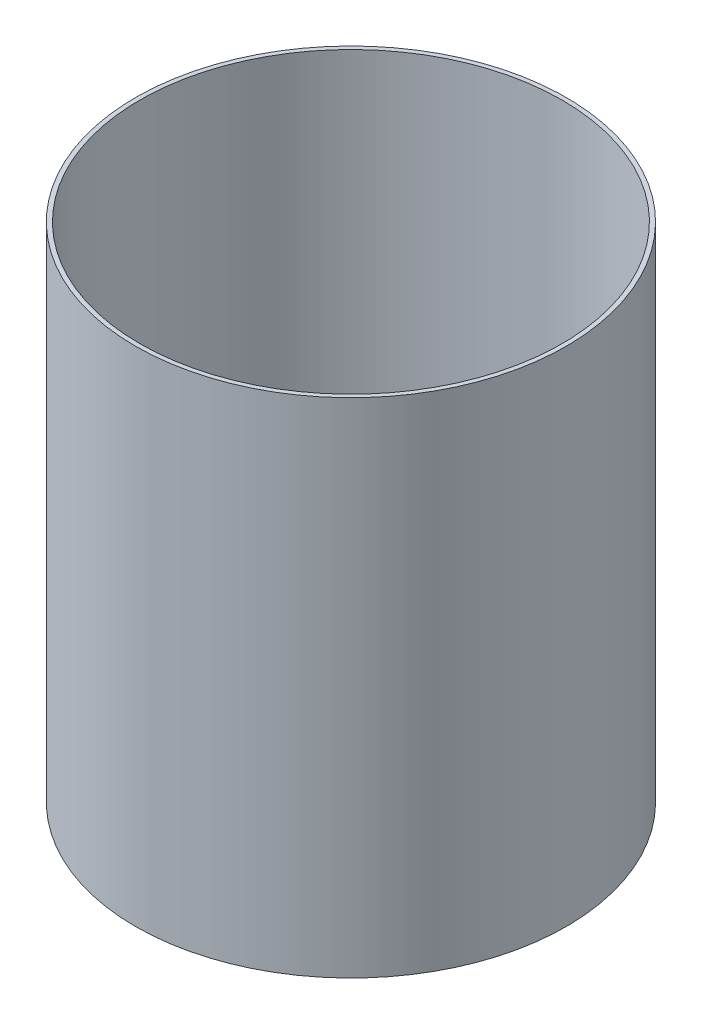
from build123d import *

# Parameters (mm, degrees)
SKETCH2_W = 1.524
SKETCH2_H = 177.8


with BuildPart() as part:
    # Sketch2 → Revolve1 (revolve)
    with BuildSketch(Plane.XY):
        with Locations((-75.438, -24.801811594)):
            Rectangle(SKETCH2_W, SKETCH2_H)
    revolve(axis=Axis((0, 64.098188406, 0), (0, -1, 0)))


solid = part.part
